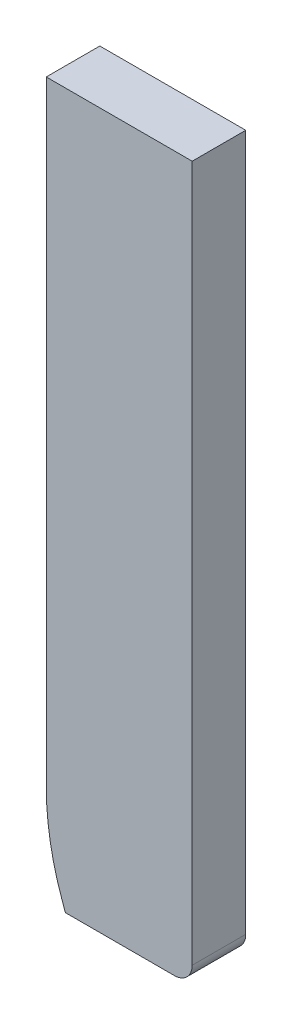
from build123d import *

# Parameters (mm, degrees)
SALIENTE_EXTRUIR1_DEPTH = 3


with BuildPart() as part:
    # Model → Saliente-Extruir1 (new body)
    with BuildSketch(Plane.XY):
        with BuildLine():
            Line((27.869611368, 31.026206242), (27.869611368, 41.227103121))
            Line((27.869611368, 41.227103121), (27.869611368, 50.428))
            Line((27.869611368, 50.428), (27.869611368, 65.428))
            Line((27.869611368, 65.428), (36.042388632, 65.428))
            Line((36.042388632, 65.428), (36.042388632, 64.428))
            Line((36.042388632, 64.428), (36.042388632, 45.928))
            Line((36.042388632, 45.928), (36.042388632, 26.428))
            ThreePointArc((36.042388632, 26.428), (35.749495414, 25.720893219), (35.042388632, 25.428))
            Line((35.042388632, 25.428), (28.941039939, 25.428))
            Line((28.941039939, 25.428), (28.743482694, 25.981160287))
            ThreePointArc((28.743482694, 25.981160287), (28.089693741, 28.466121293), (27.869611368, 31.026206242))
        make_face()
    extrude(amount=SALIENTE_EXTRUIR1_DEPTH)


solid = part.part
